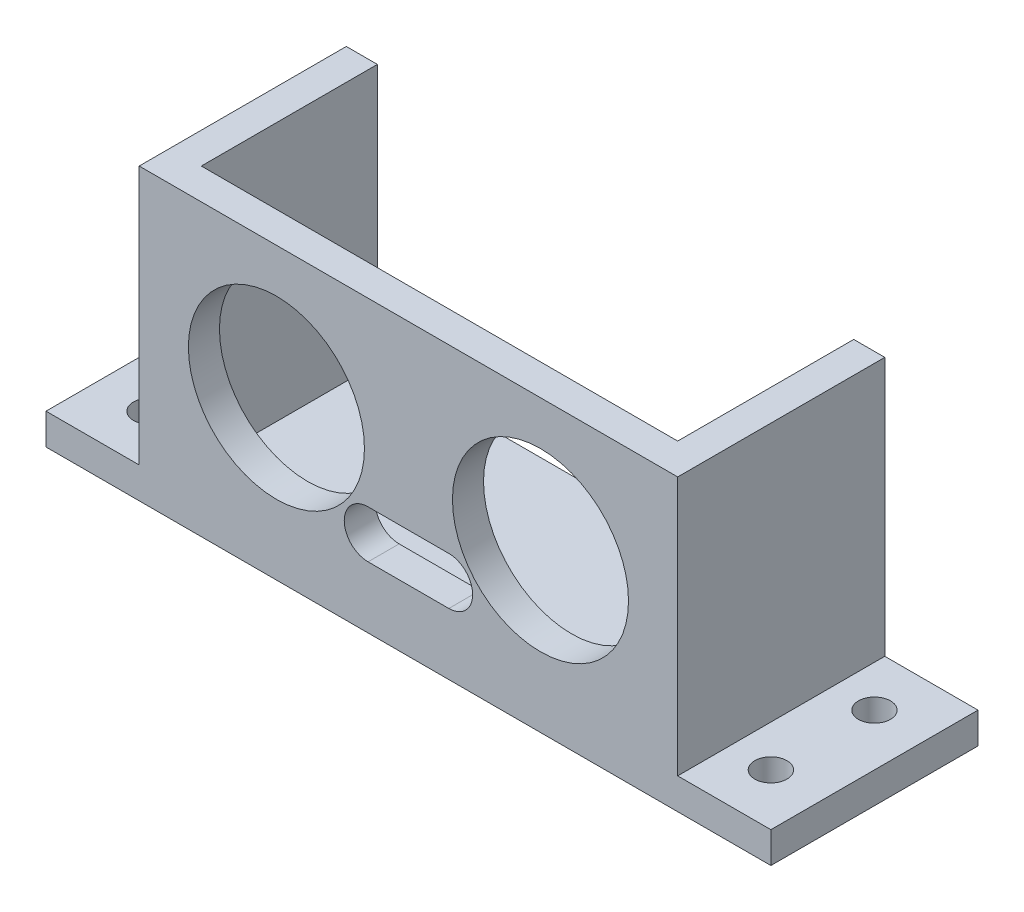
from build123d import *

# Parameters (mm, degrees)
SKETCH1_W           = 70
SKETCH1_H           = 20
SKETCH1_R           = 1.55
BOSS_EXTRUDE1_DEPTH = 3
SKETCH2_W           = 3
SKETCH2_H           = 17
SKETCH2_H_2         = 3
SKETCH2_W_2         = 46
BOSS_EXTRUDE2_DEPTH = 25
SKETCH3_R           = 8.5
CUT_EXTRUDE1_DEPTH  = 3


with BuildPart() as part:
    # Sketch1 → Boss-Extrude1 (new body)
    with BuildSketch(Plane(origin=(0, 0, 0), x_dir=(1, 0, 0), z_dir=(0, 1, 0))):
        Rectangle(SKETCH1_W, SKETCH1_H)
        with Locations((-30, -5)):
            Circle(SKETCH1_R, mode=Mode.SUBTRACT)
        with Locations((30, -5)):
            Circle(SKETCH1_R, mode=Mode.SUBTRACT)
        with Locations((30, 5)):
            Circle(SKETCH1_R, mode=Mode.SUBTRACT)
        with Locations((-30, 5)):
            Circle(SKETCH1_R, mode=Mode.SUBTRACT)
    extrude(amount=BOSS_EXTRUDE1_DEPTH)

    # Sketch2 → Boss-Extrude2 (add)
    with BuildSketch(Plane(origin=(0, 3, 0), x_dir=(1, 0, 0), z_dir=(0, 1, 0))):
        with Locations((-24.5, 1.5)):
            Rectangle(SKETCH2_W, SKETCH2_H)
        with Locations((-24.5, -8.5)):
            Rectangle(SKETCH2_W, SKETCH2_H_2)
        with Locations((0, -8.5)):
            Rectangle(SKETCH2_W_2, SKETCH2_H_2)
        with Locations((24.5, -8.5)):
            Rectangle(SKETCH2_W, SKETCH2_H_2)
        with Locations((24.5, 1.5)):
            Rectangle(SKETCH2_W, SKETCH2_H)
    extrude(amount=BOSS_EXTRUDE2_DEPTH)

    # Sketch3 → Cut-Extrude1 (cut)
    with BuildSketch(Plane.XY.offset(10)):
        with Locations((-12.75, 15.25)):
            Circle(SKETCH3_R)
        with Locations((12.75, 15.25)):
            Circle(SKETCH3_R)
        with BuildLine():
            Line((-3.9, 10.55), (3.9, 10.55))
            ThreePointArc((3.9, 10.55), (6.2, 8.25), (3.9, 5.95))
            Line((3.9, 5.95), (-3.9, 5.95))
            ThreePointArc((-3.9, 5.95), (-6.2, 8.25), (-3.9, 10.55))
        make_face()
    extrude(amount=-CUT_EXTRUDE1_DEPTH, mode=Mode.SUBTRACT)


solid = part.part
